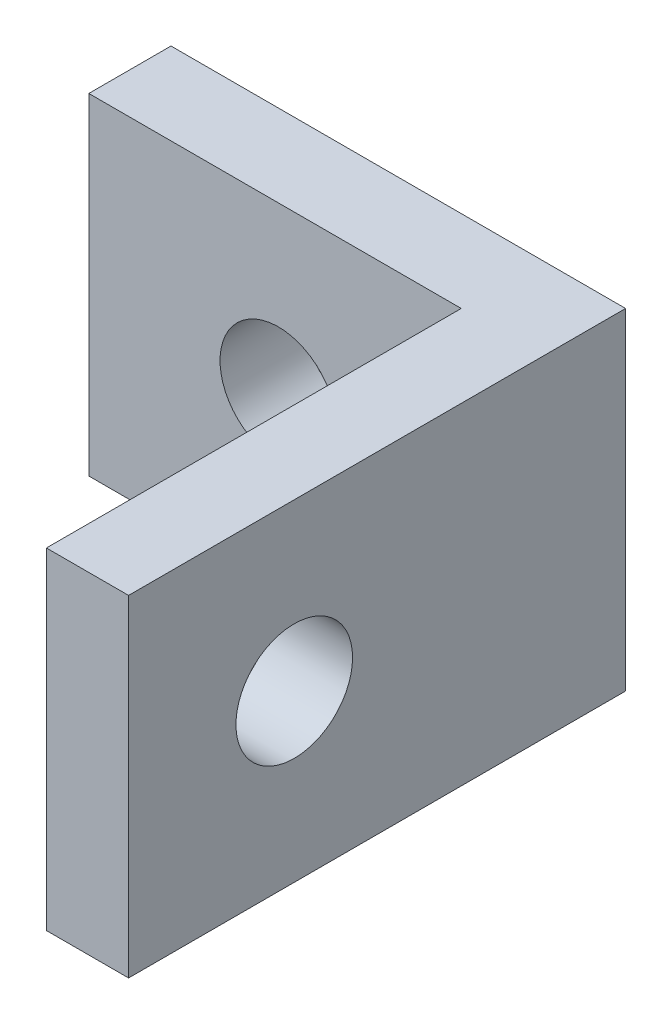
from build123d import *

# Parameters (mm, degrees)
SKETCH1_W           = 8.7122
SKETCH1_H           = 6.35
BOSS_EXTRUDE1_DEPTH = 1.5748
SKETCH2_W           = 1.5748
SKETCH2_H           = 6.35
BOSS_EXTRUDE2_DEPTH = 7.9502
SKETCH3_R           = 1.1176
CUT_EXTRUDE1_DEPTH  = 2.5748
SKETCH4_R           = 1.1176
CUT_EXTRUDE2_DEPTH  = 9.7122


with BuildPart() as part:
    # Sketch1 → Boss-Extrude1 (new body)
    with BuildSketch(Plane.XY):
        Rectangle(SKETCH1_W, SKETCH1_H)
    extrude(amount=BOSS_EXTRUDE1_DEPTH)

    # Sketch2 → Boss-Extrude2 (add)
    with BuildSketch(Plane.XY.offset(1.5748)):
        with Locations((3.5687, 0)):
            Rectangle(SKETCH2_W, SKETCH2_H)
    extrude(amount=BOSS_EXTRUDE2_DEPTH)

    # Sketch3 → Cut-Extrude1 (cut, through all)
    with BuildSketch(Plane.XY.offset(1.5748)):
        with Locations((-0.7239, 0)):
            Circle(SKETCH3_R)
    extrude(amount=-CUT_EXTRUDE1_DEPTH, mode=Mode.SUBTRACT)

    # Sketch4 → Cut-Extrude2 (cut, through all)
    with BuildSketch(Plane(origin=(4.3561, 0, 0), x_dir=(0, 0, -1), z_dir=(1, 0, 0))):
        with Locations((-6.35, 0)):
            Circle(SKETCH4_R)
    extrude(amount=-CUT_EXTRUDE2_DEPTH, mode=Mode.SUBTRACT)


solid = part.part
